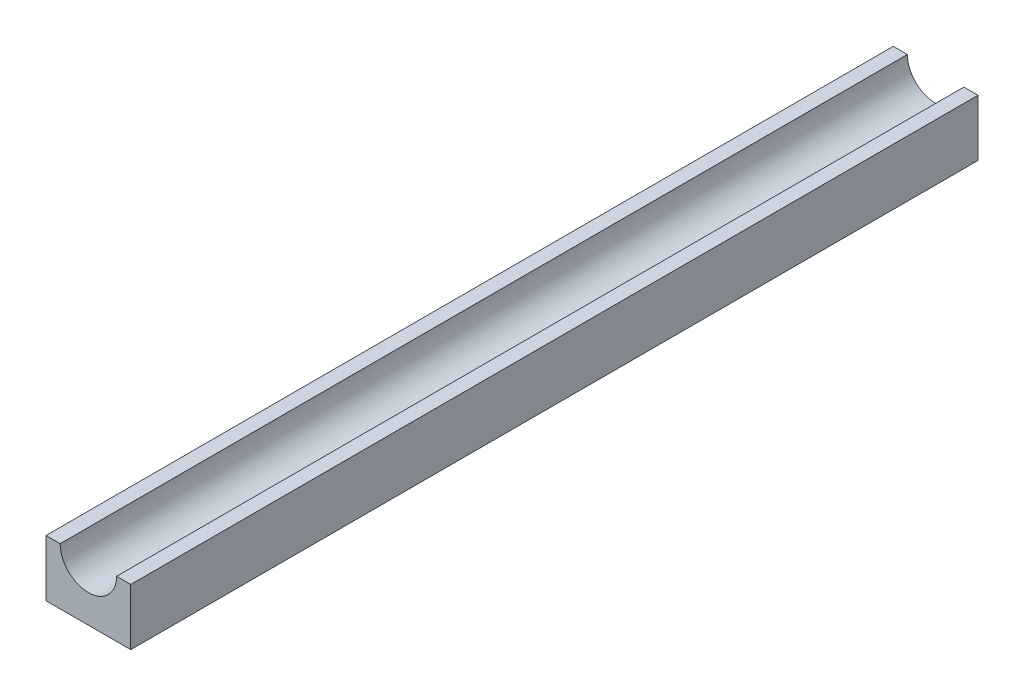
from build123d import *

# Parameters (mm, degrees)
BOSS_EXTRUDE1_DEPTH     = 150
BOSS_EXTRUDE6_DEPTH     = 1.5
SKETCH7_R               = 0.5
CUT_EXTRUDE1_DEPTH      = 8.5
CUT_EXTRUDE1_DEPTH_BACK = 8.5
SKETCH9_R               = 0.5
CUT_EXTRUDE2_DEPTH      = 10


with BuildPart() as part:
    # Sketch1 → Boss-Extrude1 (new body)
    with BuildSketch(Plane.XY):
        with BuildLine():
            Line((7.5, 5), (5, 5))
            ThreePointArc((5, 5), (0, 0), (-5, 5))
            Line((-5, 5), (-7.5, 5))
            Line((-7.5, 5), (-7.5, -5))
            Line((-7.5, -5), (7.5, -5))
            Line((7.5, -5), (7.5, 5))
        make_face()
    extrude(amount=BOSS_EXTRUDE1_DEPTH)

    # Sketch6 → Boss-Extrude6 (add, symmetric)
    with BuildSketch(Plane.ZY):
        with BuildLine():
            ThreePointArc((77.5, -8), (75, -5.5), (72.5, -8))
            Line((72.5, -8), (77.5, -8))
        make_face()
        with BuildLine():
            Line((77.5, -8), (72.5, -8))
            ThreePointArc((72.5, -8), (75, -10.5), (77.5, -8))
        make_face()
        with BuildLine():
            Line((77.5, -5), (72.5, -5))
            Line((72.5, -5), (72.5, -8))
            ThreePointArc((72.5, -8), (75, -5.5), (77.5, -8))
            Line((77.5, -8), (77.5, -5))
        make_face()
    boss_extrude6 = extrude(amount=BOSS_EXTRUDE6_DEPTH, both=True)

    # Mirror1: Boss-Extrude6 across plane
    add(boss_extrude6.mirror(Plane(origin=(0, 0, 45), x_dir=(1, 0, 0), z_dir=(0, 0, -1))))

    # Sketch7 → Cut-Extrude1 (cut, two sides)
    with BuildSketch(Plane.ZY) as cut_extrude1_sk:
        with Locations((75, -8)):
            Circle(SKETCH7_R)
    extrude(amount=CUT_EXTRUDE1_DEPTH, mode=Mode.SUBTRACT)
    extrude(cut_extrude1_sk.sketch, amount=-CUT_EXTRUDE1_DEPTH_BACK, mode=Mode.SUBTRACT)

    # Sketch9 → Cut-Extrude2 (cut)
    with BuildSketch(Plane.ZY.offset(1.5)):
        with Locations((15, -8)):
            Circle(SKETCH9_R)
    extrude(amount=-CUT_EXTRUDE2_DEPTH, mode=Mode.SUBTRACT)


solid = part.part
